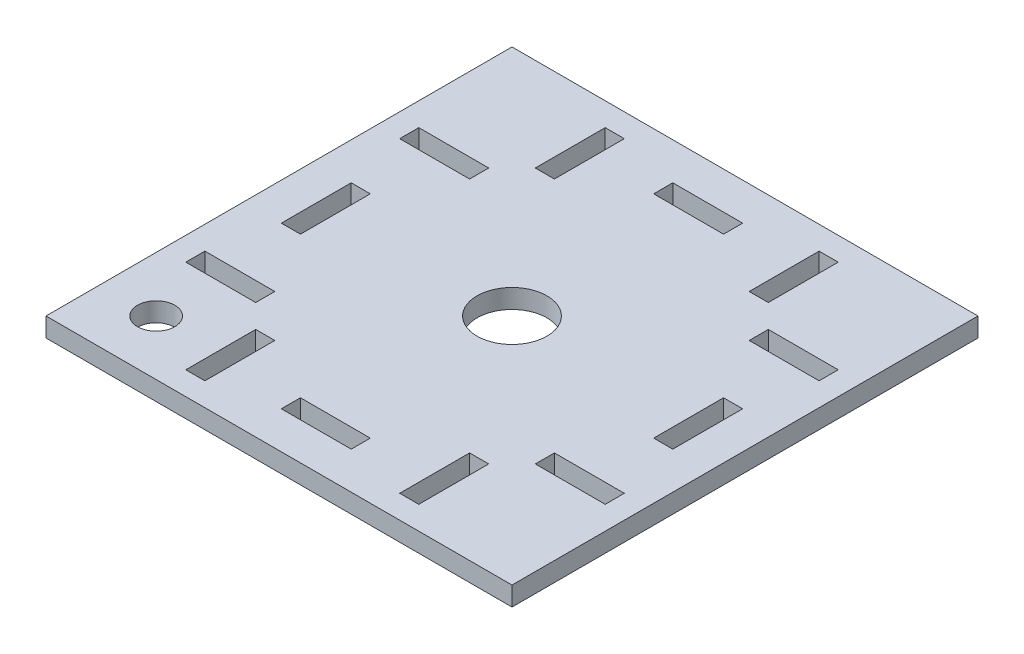
from build123d import *

# Parameters (mm, degrees)
SKETCH1_W           = 100
SKETCH1_H           = 100
SKETCH1_R           = 7.5
SKETCH1_R_2         = 4
SKETCH1_W_2         = 4.1
SKETCH1_H_2         = 15
SKETCH1_W_3         = 15
SKETCH1_H_3         = 4.1
BOSS_EXTRUDE1_DEPTH = 4.1


with BuildPart() as part:
    # Sketch1 → Boss-Extrude1 (new body)
    with BuildSketch(Plane(origin=(0, 0, 0), x_dir=(1, 0, 0), z_dir=(0, 1, 0))):
        Rectangle(SKETCH1_W, SKETCH1_H)
        Circle(SKETCH1_R, mode=Mode.SUBTRACT)
        with Locations((-38.183766184, -38.183766184)):
            Circle(SKETCH1_R_2, mode=Mode.SUBTRACT)
        with Locations((-22.95, 37.5)):
            Rectangle(SKETCH1_W_2, SKETCH1_H_2, mode=Mode.SUBTRACT)
        with Locations((-37.5, 22.95)):
            Rectangle(SKETCH1_W_3, SKETCH1_H_3, mode=Mode.SUBTRACT)
        with Locations((37.5, -22.95)):
            Rectangle(SKETCH1_W_3, SKETCH1_H_3, mode=Mode.SUBTRACT)
        with Locations((22.95, -37.5)):
            Rectangle(SKETCH1_W_2, SKETCH1_H_2, mode=Mode.SUBTRACT)
        with Locations((37.5, 22.95)):
            Rectangle(SKETCH1_W_3, SKETCH1_H_3, mode=Mode.SUBTRACT)
        with Locations((-37.5, -22.95)):
            Rectangle(SKETCH1_W_3, SKETCH1_H_3, mode=Mode.SUBTRACT)
        with Locations((22.95, 37.5)):
            Rectangle(SKETCH1_W_2, SKETCH1_H_2, mode=Mode.SUBTRACT)
        with Locations((-22.95, -37.5)):
            Rectangle(SKETCH1_W_2, SKETCH1_H_2, mode=Mode.SUBTRACT)
        with Locations((0, 39.95)):
            Rectangle(SKETCH1_W_3, SKETCH1_H_3, mode=Mode.SUBTRACT)
        with Locations((0, -39.95)):
            Rectangle(SKETCH1_W_3, SKETCH1_H_3, mode=Mode.SUBTRACT)
        with Locations((39.95, 0)):
            Rectangle(SKETCH1_W_2, SKETCH1_H_2, mode=Mode.SUBTRACT)
        with Locations((-39.95, 0)):
            Rectangle(SKETCH1_W_2, SKETCH1_H_2, mode=Mode.SUBTRACT)
    extrude(amount=BOSS_EXTRUDE1_DEPTH)


solid = part.part
